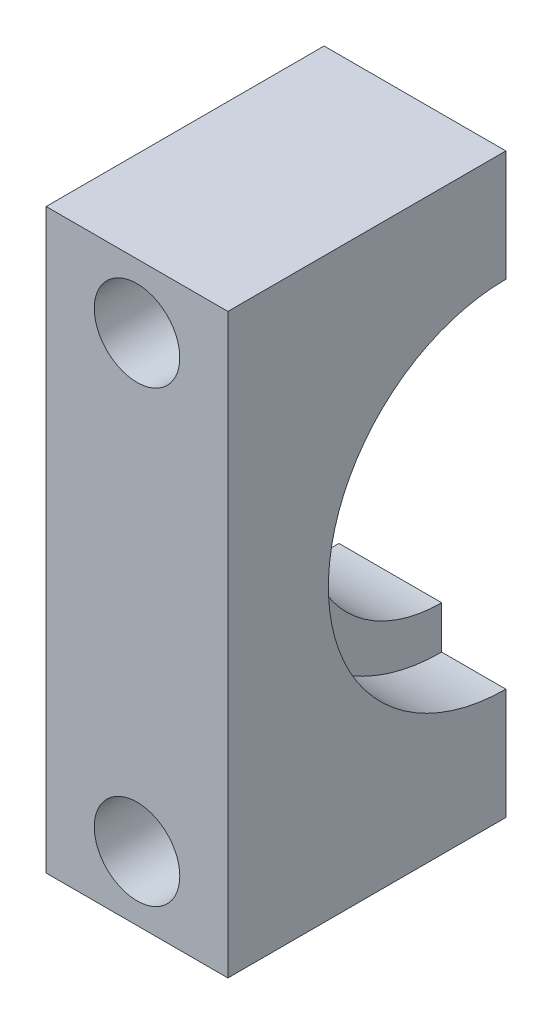
from build123d import *

# Parameters (mm, degrees)
ESBO_O1_W                = 8.5
ESBO_O1_H                = 27
RESSALTO_EXTRUS_O1_DEPTH = 13
ESBO_O3_R                = 8.3
CORTE_EXTRUS_O1_DEPTH    = 3
ESBO_O4_R                = 6.3
CORTE_EXTRUS_O2_DEPTH    = 5
ESBO_O7_R                = 8.3
CORTE_EXTRUS_O3_DEPTH    = 0.7
ESBO_O8_R                = 2
CORTE_EXTRUS_O4_DEPTH    = 14


with BuildPart() as part:
    # Esboço1 → Ressalto-extrusão1 (new body)
    with BuildSketch(Plane.XY):
        with Locations((4.75, 202.468429513)):
            Rectangle(ESBO_O1_W, ESBO_O1_H)
    extrude(amount=RESSALTO_EXTRUS_O1_DEPTH)

    # Esboço3 → Corte-extrusão1 (cut)
    with BuildSketch(Plane(origin=(9, 0, 0), x_dir=(0, 0, -1), z_dir=(1, 0, 0))):
        with Locations((0, 202.468429513)):
            Circle(ESBO_O3_R)
    extrude(amount=-CORTE_EXTRUS_O1_DEPTH, mode=Mode.SUBTRACT)

    # Esboço4 → Corte-extrusão2 (cut)
    with BuildSketch(Plane(origin=(6, 0, 0), x_dir=(0, 0, -1), z_dir=(1, 0, 0))):
        with Locations((0, 202.468429513)):
            Circle(ESBO_O4_R)
    extrude(amount=-CORTE_EXTRUS_O2_DEPTH, mode=Mode.SUBTRACT)

    # Esboço7 → Corte-extrusão3 (cut)
    with BuildSketch(Plane.ZY.offset(-0.5)):
        with Locations((0, 202.468429513)):
            Circle(ESBO_O7_R)
    extrude(amount=-CORTE_EXTRUS_O3_DEPTH, mode=Mode.SUBTRACT)

    # Esboço8 → Corte-extrusão4 (cut, through all)
    with BuildSketch(Plane.XY.offset(13)):
        with Locations((4.75, 191.968429513)):
            Circle(ESBO_O8_R)
        with Locations((4.75, 212.968429513)):
            Circle(ESBO_O8_R)
    extrude(amount=-CORTE_EXTRUS_O4_DEPTH, mode=Mode.SUBTRACT)


solid = part.part
